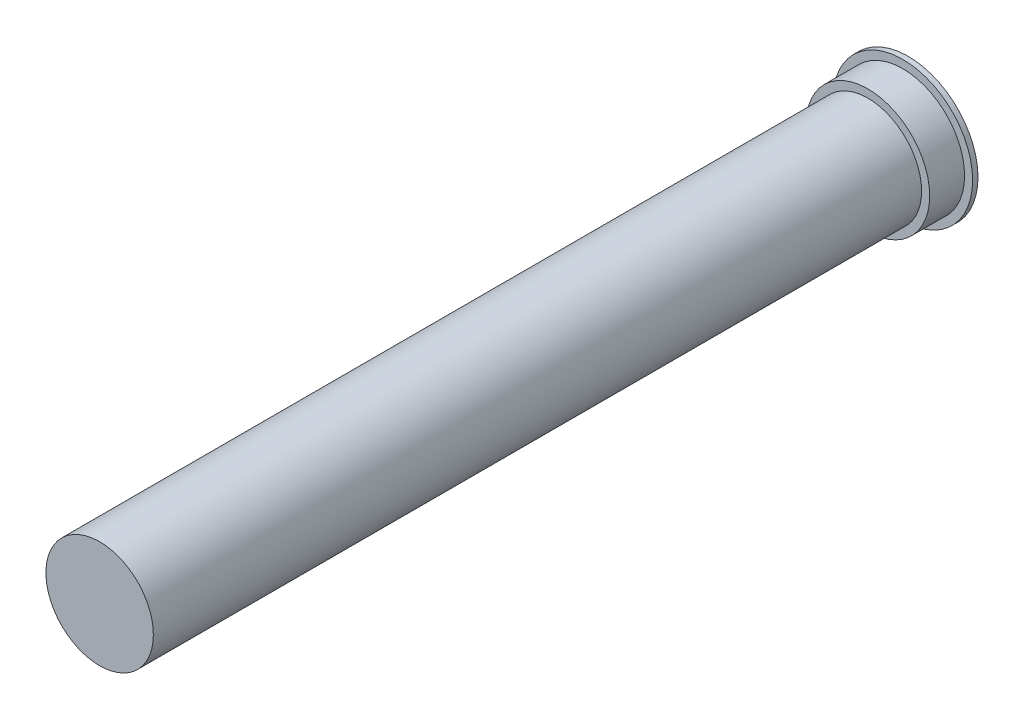
from build123d import *

# Parameters (mm, degrees)
SKETCH2_R           = 20
SKETCH2_R_2         = 19
BOSS_EXTRUDE1_DEPTH = 300
SKETCH3_R           = 20
BOSS_EXTRUDE2_DEPTH = 1
SKETCH2_4_R         = 23
SKETCH2_4_R_2       = 20
BOSS_EXTRUDE3_DEPTH = 15
SKETCH2_5_R         = 26
SKETCH2_5_R_2       = 23
BOSS_EXTRUDE4_DEPTH = 2


with BuildPart() as part:
    # Sketch2 → Boss-Extrude1 (new body)
    with BuildSketch(Plane.XY):
        Circle(SKETCH2_R)
        Circle(SKETCH2_R_2, mode=Mode.SUBTRACT)
    extrude(amount=BOSS_EXTRUDE1_DEPTH)

    # Sketch3 → Boss-Extrude2 (add)
    with BuildSketch(Plane.XY.offset(300)):
        Circle(SKETCH3_R)
    extrude(amount=BOSS_EXTRUDE2_DEPTH)

    # Sketch2_4 → Boss-Extrude3 (add)
    with BuildSketch(Plane.XY):
        Circle(SKETCH2_4_R)
        Circle(SKETCH2_4_R_2, mode=Mode.SUBTRACT)
    extrude(amount=BOSS_EXTRUDE3_DEPTH)

    # Sketch2_5 → Boss-Extrude4 (add)
    with BuildSketch(Plane.XY):
        Circle(SKETCH2_5_R)
        Circle(SKETCH2_5_R_2, mode=Mode.SUBTRACT)
    extrude(amount=BOSS_EXTRUDE4_DEPTH)


solid = part.part
